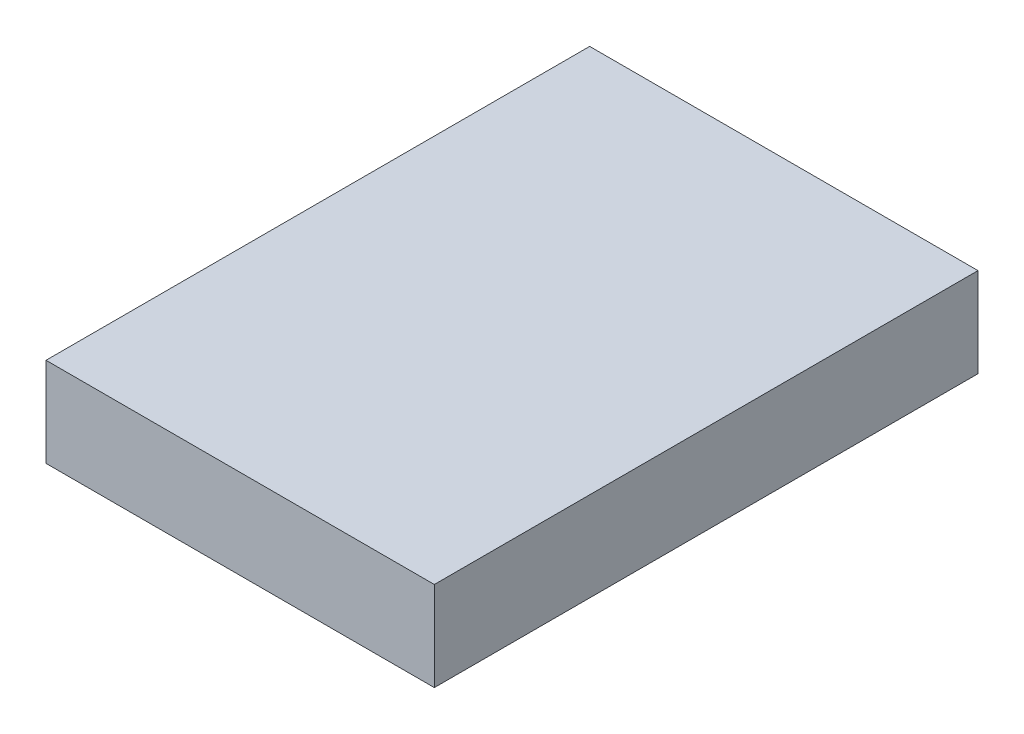
from build123d import *

# Parameters (mm, degrees)
SKETCH1_W           = 25
SKETCH1_H           = 35
BOSS_EXTRUDE1_DEPTH = 5.75


with BuildPart() as part:
    # Sketch1 → Boss-Extrude1 (new body)
    with BuildSketch(Plane(origin=(0, 0, 0), x_dir=(1, 0, 0), z_dir=(0, 1, 0))):
        with Locations((10.412371134, 1.353092784)):
            Rectangle(SKETCH1_W, SKETCH1_H)
    extrude(amount=BOSS_EXTRUDE1_DEPTH)


solid = part.part
